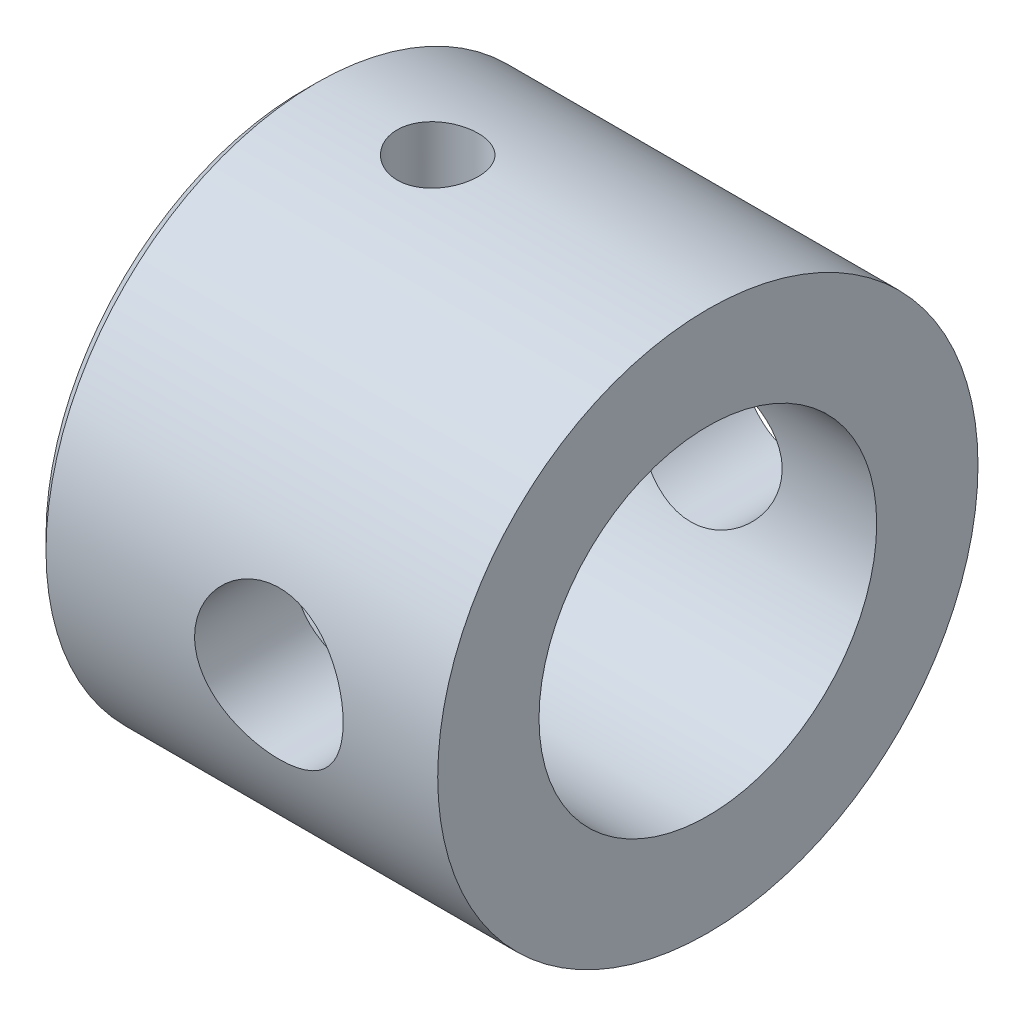
from build123d import *

# Parameters (mm, degrees)
SKETCH2_R               = 6
CUT_EXTRUDE1_DEPTH      = 41
CUT_EXTRUDE1_DEPTH_BACK = 41
SKETCH3_R               = 11
CUT_EXTRUDE2_DEPTH      = 41.0000001
CUT_EXTRUDE2_DEPTH_BACK = 41.0000001


with BuildPart() as part:
    # Sketch1 → Revolve1 (revolve)
    with BuildSketch(Plane.XY):
        Polygon((2, 40), (60, 40), (60, 25), (2, 25), (0, 27), (0, 38), align=None)
    revolve(axis=Axis((0, 0, 0), (1, 0, 0)))

    # Sketch2 → Cut-Extrude1 (cut, two sides)
    with BuildSketch(Plane(origin=(0, 0, 0), x_dir=(1, 0, 0), z_dir=(0, 1, 0))) as cut_extrude1_sk:
        with Locations((20, 0)):
            Circle(SKETCH2_R)
    extrude(amount=CUT_EXTRUDE1_DEPTH, mode=Mode.SUBTRACT)
    extrude(cut_extrude1_sk.sketch, amount=-CUT_EXTRUDE1_DEPTH_BACK, mode=Mode.SUBTRACT)

    # Sketch3 → Cut-Extrude2 (cut, two sides)
    with BuildSketch(Plane.XY) as cut_extrude2_sk:
        with Locations((35, 0)):
            Circle(SKETCH3_R)
    extrude(amount=CUT_EXTRUDE2_DEPTH, mode=Mode.SUBTRACT)
    extrude(cut_extrude2_sk.sketch, amount=-CUT_EXTRUDE2_DEPTH_BACK, mode=Mode.SUBTRACT)


solid = part.part
